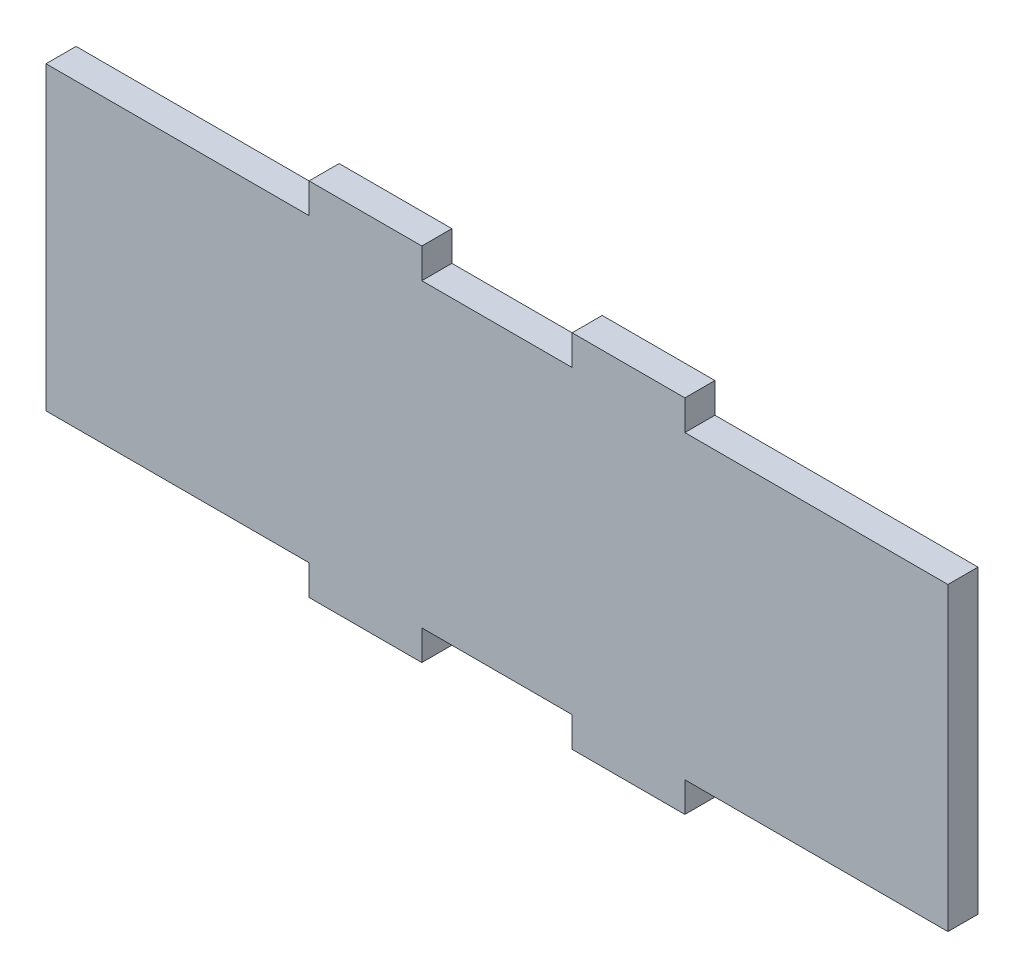
from build123d import *

# Parameters (mm, degrees)
SKETCH1_W           = 120
SKETCH1_H           = 4
BOSS_EXTRUDE3_DEPTH = 48
SKETCH4_W           = 35
SKETCH4_H           = 4
SKETCH4_W_2         = 20
CUT_EXTRUDE2_DEPTH  = 48


with BuildPart() as part:
    # Sketch1 → Boss-Extrude3 (new body)
    with BuildSketch(Plane(origin=(0, 0, 0), x_dir=(1, 0, 0), z_dir=(0, 1, 0))):
        Rectangle(SKETCH1_W, SKETCH1_H)
    extrude(amount=BOSS_EXTRUDE3_DEPTH)

    # Sketch4 → Cut-Extrude2 (cut)
    with BuildSketch(Plane.XY.offset(2)):
        with Locations((-42.5, 46)):
            Rectangle(SKETCH4_W, SKETCH4_H)
        with Locations((0, 46)):
            Rectangle(SKETCH4_W_2, SKETCH4_H)
        with Locations((42.5, 46)):
            Rectangle(SKETCH4_W, SKETCH4_H)
        with Locations((-42.5, 2)):
            Rectangle(SKETCH4_W, SKETCH4_H)
        with Locations((0, 2)):
            Rectangle(SKETCH4_W_2, SKETCH4_H)
        with Locations((42.5, 2)):
            Rectangle(SKETCH4_W, SKETCH4_H)
    extrude(amount=-CUT_EXTRUDE2_DEPTH, mode=Mode.SUBTRACT)


solid = part.part
